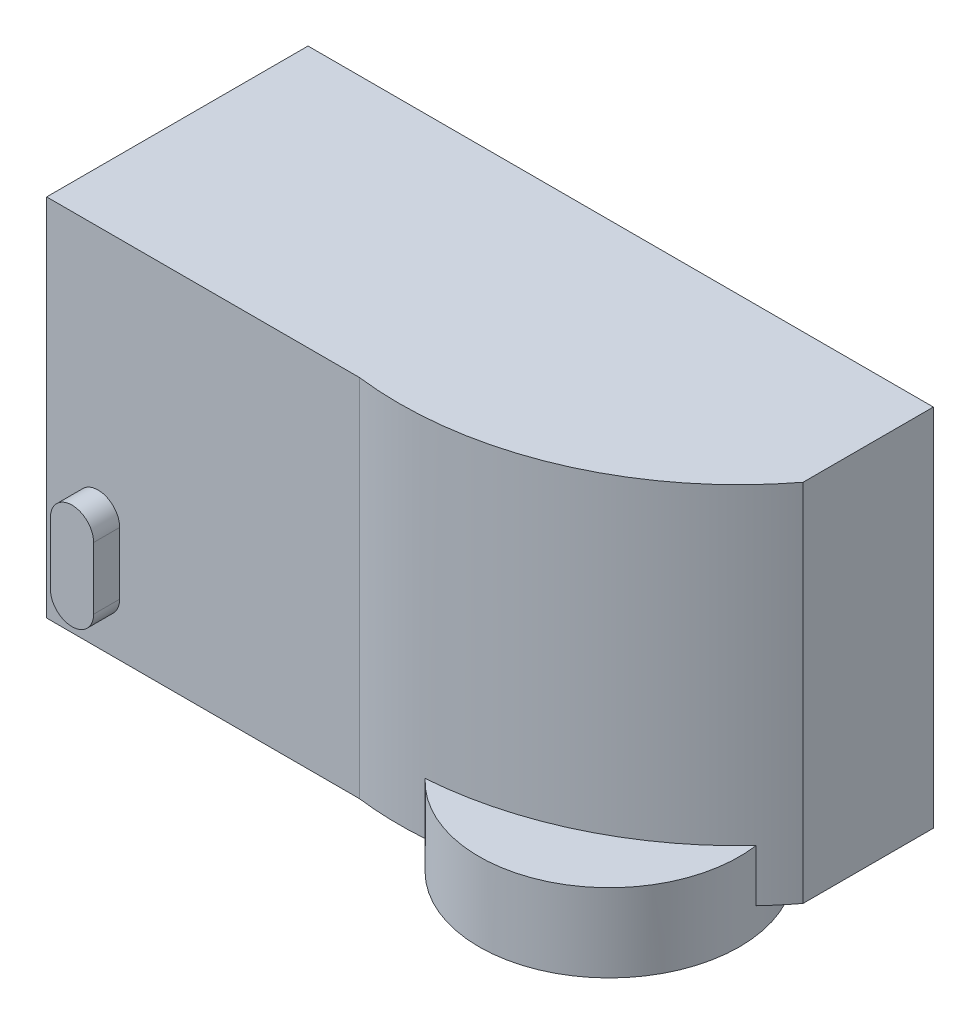
from build123d import *

# Parameters (mm, degrees)
SKETCH4_W                = 120
SKETCH4_H                = 70
BOSS_EXTRUDE1_DEPTH      = 10
SKETCH5_R                = 5
CUT_EXTRUDE1_DEPTH       = 40
BOSS_EXTRUDE2_DEPTH      = 70
SKETCH9_R                = 5
CUT_EXTRUDE2_DEPTH       = 15
SKETCH11_R               = 25
BOSS_EXTRUDE3_DEPTH      = 5
BOSS_EXTRUDE3_DEPTH_BACK = 10
SKETCH12_R               = 5
CUT_EXTRUDE3_DEPTH       = 7
BOSS_EXTRUDE5_DEPTH      = 5
SKETCH15_W               = 4.5
SKETCH15_H               = 10
CUT_EXTRUDE4_DEPTH       = 8
SKETCH16_W               = 1.569022944
SKETCH16_H               = 8.700945414
SKETCH16_W_2             = 1.426384494
BOSS_EXTRUDE6_DEPTH      = 8
SKETCH17_W               = 40.700182708
SKETCH17_H               = 28.264015769
BOSS_EXTRUDE7_DEPTH      = 1
BOSS_EXTRUDE8_DEPTH      = 1.5


with BuildPart() as part:
    # Sketch4 → Boss-Extrude1 (new body)
    with BuildSketch(Plane.XY):
        Rectangle(SKETCH4_W, SKETCH4_H)
    extrude(amount=-BOSS_EXTRUDE1_DEPTH)

    # Sketch5 → Cut-Extrude1 (cut)
    with BuildSketch(Plane.XY):
        Circle(SKETCH5_R)
    extrude(amount=-CUT_EXTRUDE1_DEPTH, mode=Mode.SUBTRACT)

    # Sketch8 → Boss-Extrude2 (add)
    with BuildSketch(Plane.XZ.offset(35)):
        with BuildLine():
            Line((-60, -10), (-60, 40.154750478))
            Line((-60, 40.154750478), (0, 40.154750478))
            ThreePointArc((0, 40.154750478), (33.3625471, 35.597841439), (60, 15))
            Line((60, 15), (60, -10))
            Line((60, -10), (-60, -10))
        make_face()
    extrude(amount=-BOSS_EXTRUDE2_DEPTH)

    # Sketch9 → Cut-Extrude2 (cut)
    with BuildSketch(Plane(origin=(0, 0, -10), x_dir=(-1, 0, 0), z_dir=(0, 0, -1))):
        Circle(SKETCH9_R)
    extrude(amount=-CUT_EXTRUDE2_DEPTH, mode=Mode.SUBTRACT)

    # Sketch11 → Boss-Extrude3 (add, two sides)
    with BuildSketch(Plane.XZ.offset(35)) as boss_extrude3_sk:
        with Locations((31.117439105, 23.306323577)):
            Circle(SKETCH11_R)
    extrude(amount=BOSS_EXTRUDE3_DEPTH)
    extrude(boss_extrude3_sk.sketch, amount=-BOSS_EXTRUDE3_DEPTH_BACK)

    # Sketch12 → Cut-Extrude3 (cut)
    with BuildSketch(Plane.XZ.offset(40)):
        with Locations((31.117439105, 23.306323577)):
            Circle(SKETCH12_R)
    extrude(amount=-CUT_EXTRUDE3_DEPTH, mode=Mode.SUBTRACT)

    # Sketch14 → Boss-Extrude5 (add)
    with BuildSketch(Plane.XY.offset(40.154750478)):
        with BuildLine():
            Line((-45.98826123, -12.928324025), (-45.98826123, -24.846408626))
            ThreePointArc((-45.98826123, -24.846408626), (-50.13368196, -28.991829356), (-54.279102691, -24.846408626))
            Line((-54.279102691, -24.846408626), (-54.279102691, -12.928324025))
            ThreePointArc((-54.279102691, -12.928324025), (-50.13368196, -8.782903295), (-45.98826123, -12.928324025))
        make_face()
    extrude(amount=BOSS_EXTRUDE5_DEPTH)

    # Sketch15 → Cut-Extrude4 (cut)
    with BuildSketch(Plane.ZY.offset(60)):
        with Locations((-0.699635799, 23.193765021)):
            Rectangle(SKETCH15_W, SKETCH15_H)
        with Locations((6.524606685, 23.193765021)):
            Rectangle(SKETCH15_W, SKETCH15_H)
    extrude(amount=-CUT_EXTRUDE4_DEPTH, mode=Mode.SUBTRACT)

    # Sketch16 → Boss-Extrude6 (add)
    with BuildSketch(Plane.ZY.offset(52)):
        with Locations((-1.63562366, 23.437743986)):
            Rectangle(SKETCH16_W, SKETCH16_H)
        with Locations((5.710256485, 23.437743986)):
            Rectangle(SKETCH16_W_2, SKETCH16_H)
    extrude(amount=BOSS_EXTRUDE6_DEPTH)

    # Sketch17 → Boss-Extrude7 (add)
    with BuildSketch(Plane.ZY.offset(60)):
        with Locations((16.084407409, -14.726216905)):
            Rectangle(SKETCH17_W, SKETCH17_H)
    extrude(amount=BOSS_EXTRUDE7_DEPTH)

    # Sketch18 → Boss-Extrude8 (add)
    with BuildSketch(Plane.ZY.offset(61)):
        Polygon((-0.506912877, -8.264193133), (2.379724675, -8.289824612), (3.845240963, -5.802738899), (2.424119698, -3.290021707), (-0.462517855, -3.264390229), (-1.928034142, -5.751475942), align=None)
        Polygon((34.09684896, -5.751475942), (32.675727695, -8.264193133), (29.789090142, -8.289824612), (28.323573855, -5.802738899), (29.74469512, -3.290021707), (32.631332673, -3.264390229), align=None)
        Polygon((-1.928034142, -23.700957867), (-0.506912877, -21.188240676), (2.379724675, -21.162609198), (3.845240963, -23.649694911), (2.424119698, -26.162412102), (-0.462517855, -26.18804358), align=None)
        Polygon((32.675727695, -21.188240676), (29.789090142, -21.162609198), (28.323573855, -23.649694911), (29.74469512, -26.162412102), (32.631332673, -26.18804358), (34.09684896, -23.700957867), align=None)
    extrude(amount=BOSS_EXTRUDE8_DEPTH)


solid = part.part
